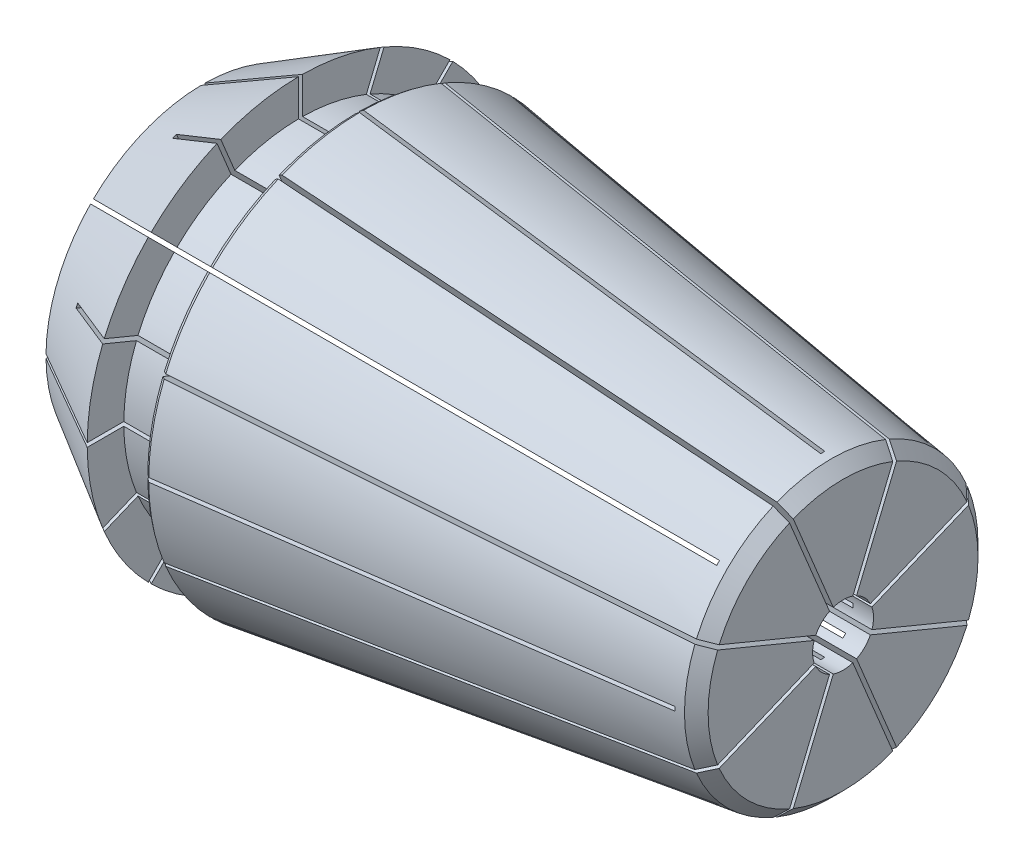
from build123d import *
from OCP.BRepFilletAPI import BRepFilletAPI_MakeChamfer

# Parameters (mm, degrees)
SKETCH2_R               = 10.5
BOSS_EXTRUDE1_DEPTH     = 31.5
CUT_EXTRUDE1_DEPTH      = 30.5
CUT_EXTRUDE2_DEPTH      = 29.5
CHAMFER_1_SIZE          = 0.5
CHAMFER_2_SIZE          = 0.2
CHAMFER_2_SIZE2         = 0.17707872296955127
CHAMFER_2_EDGE_2_SIZE   = 0.2
CHAMFER_2_EDGE_2_SIZE2  = 0.17707872296955127
CHAMFER_2_EDGE_3_SIZE2  = 0.17707872296955127
CHAMFER_2_EDGE_3_SIZE   = 0.2
CHAMFER_2_EDGE_4_SIZE2  = 0.17707872296955127
CHAMFER_2_EDGE_4_SIZE   = 0.2
CHAMFER_2_EDGE_5_SIZE2  = 0.17707872296955127
CHAMFER_2_EDGE_5_SIZE   = 0.2
CHAMFER_2_EDGE_6_SIZE2  = 0.17707872296955127
CHAMFER_2_EDGE_6_SIZE   = 0.2
CHAMFER_2_EDGE_7_SIZE2  = 0.17707872296955127
CHAMFER_2_EDGE_7_SIZE   = 0.2
CHAMFER_2_EDGE_8_SIZE2  = 0.17707872296955127
CHAMFER_2_EDGE_8_SIZE   = 0.2
CHAMFER_2_EDGE_9_SIZE2  = 0.17707872296955127
CHAMFER_2_EDGE_9_SIZE   = 0.2
CHAMFER_2_EDGE_10_SIZE2 = 0.17707872296955127
CHAMFER_2_EDGE_10_SIZE  = 0.2
CHAMFER_2_EDGE_11_SIZE2 = 0.17707872296955127
CHAMFER_2_EDGE_11_SIZE  = 0.2
CHAMFER_2_EDGE_12_SIZE2 = 0.17707872296955127
CHAMFER_2_EDGE_12_SIZE  = 0.2
CHAMFER_2_EDGE_13_SIZE2 = 0.17707872296955127
CHAMFER_2_EDGE_13_SIZE  = 0.2
CHAMFER_2_EDGE_14_SIZE2 = 0.17707872296955127
CHAMFER_2_EDGE_14_SIZE  = 0.2
CHAMFER_2_EDGE_15_SIZE2 = 0.17707872296955124
CHAMFER_2_EDGE_15_SIZE  = 0.2
CHAMFER_2_EDGE_16_SIZE2 = 0.17707872296955127
CHAMFER_2_EDGE_16_SIZE  = 0.2
CHAMFER_3_SIZE          = 0.5
CHAMFER_3_SIZE2         = 0.5874785058397357


with BuildPart() as part:
    # Sketch2 → Boss-Extrude1 (new body)
    with BuildSketch(Plane(origin=(0, 0, 0), x_dir=(0, 0, -1), z_dir=(1, 0, 0))):
        Circle(SKETCH2_R)
    extrude(amount=BOSS_EXTRUDE1_DEPTH)

    # Sketch3 → Cut-Revolve1 (revolve, cut)
    with BuildSketch(Plane.XY, mode=Mode.PRIVATE) as cut_revolve1_sk:
        Polygon((0, 7.7287187078898345), (4.799999999999999, 10.5), (4.8, 8.7), (7.602315138807671, 8.7), (7.602315138807672, 10.5), (31.5, 7.141399422153533), (31.5, 15.5), (0, 15.499999999999996), align=None)
        Polygon((0, 0), (31.5, 0), (31.5, 1.4999999999999993), (0, 1.5), align=None)
    revolve(cut_revolve1_sk.sketch.rotate(Axis((0, 0, 0), (1, 0, 0)), 90), axis=Axis((0, 0, 0), (1, 0, 0)), mode=Mode.SUBTRACT)

    # Sketch4 → Cut-Extrude1 (cut)
    with BuildSketch(Plane.ZY):
        Polygon((21.849599538664314, 21.991020894901638), (21.99102089490162, 21.849599538664325), (-21.849599538664314, -21.991020894901634), (-21.991020894901624, -21.84959953866433), align=None)
        Polygon((-0.10000000000000568, 31), (0.09999999999999433, 31), (0.1000000000000019, -31), (-0.0999999999999981, -31), align=None)
        Polygon((31, 0.10000000000000756), (31, -0.09999999999999246), (-31, -0.10000000000001143), (-31, 0.09999999999998858), align=None)
        Polygon((21.991020894901634, -21.84959953866431), (21.849599538664325, -21.99102089490162), (-21.991020894901634, 21.84959953866431), (-21.849599538664325, 21.991020894901617), align=None)
    extrude(amount=-CUT_EXTRUDE1_DEPTH, mode=Mode.SUBTRACT)

    # Sketch5 → Cut-Extrude2 (cut)
    with BuildSketch(Plane(origin=(31.5, 0, 0), x_dir=(0, 0, -1), z_dir=(1, 0, 0))):
        Polygon((-11.95557435660571, -28.601997164702777), (-11.770798450103456, -28.67853385117579), (11.955574356605666, 28.601997164702674), (11.770798450103404, 28.67853385117568), align=None)
        Polygon((28.60199716470252, 11.95557435660602), (28.678533851175544, 11.770798450103763), (-28.60199716470259, -11.955574356606142), (-28.678533851175608, -11.770798450103886), align=None)
        Polygon((28.678533851175693, -11.770798450103486), (28.601997164702688, -11.955574356605748), (-28.67853385117578, 11.77079845010337), (-28.601997164702762, 11.955574356605625), align=None)
        Polygon((11.955574356606032, -28.601997164702603), (11.770798450103777, -28.67853385117563), (-11.955574356606128, 28.601997164702507), (-11.770798450103872, 28.678533851175526), align=None)
    extrude(amount=-CUT_EXTRUDE2_DEPTH, mode=Mode.SUBTRACT)

    # Фаска1
    chamfer_1_edges = [part.edges().sort_by_distance(p)[0] for p in [
        (0, 1.3858192987669309, 0.5740251485476324),
        (0, 1.3858192987669282, -0.5740251485476393),
        (0, 0.5740251485476435, -1.3858192987669264),
        (0, -0.5740251485476404, -1.3858192987669278),
        (0, -1.3858192987669284, -0.5740251485476388),
        (0, -1.3858192987669316, 0.5740251485476311),
        (0, -0.574025148547668, 1.3858192987669162),
        (0, 0.5740251485476455, 1.3858192987669256),
    ]]
    chamfer(chamfer_1_edges, length=CHAMFER_1_SIZE)

    # Фаска2
    chamfer_2_edges = [part.edges().sort_by_distance(p)[0] for p in [
        (7.602315138807672, 2.048448381169277, 10.298245444233935),
    ]]
    chamfer_2_side = [part.faces().sort_by_distance(p)[0] for p in [
        (19.5511575694038, -1.0654e-13, 8.820699711076772),
    ]]
    chamfer(chamfer_2_edges, length=CHAMFER_2_SIZE, length2=CHAMFER_2_SIZE2, reference=chamfer_2_side[0])

    # Фаска2 edge 2
    chamfer_2_edge_2_edges = [part.edges().sort_by_distance(p)[0] for p in [
        (7.602315138807672, -2.048448381169412, 10.298245444233906),
    ]]
    chamfer_2_edge_2_side = [part.faces().sort_by_distance(p)[0] for p in [
        (19.5511575694038, -1.0654e-13, 8.820699711076772),
    ]]
    chamfer(chamfer_2_edge_2_edges, length=CHAMFER_2_EDGE_2_SIZE, length2=CHAMFER_2_EDGE_2_SIZE2, reference=chamfer_2_edge_2_side[0])

    # Фаска2 edge 3
    chamfer_2_edge_3_edges = [part.edges().sort_by_distance(p)[0] for p in [
        (7.602315138807672, -10.298245444233917, -2.0484483811693566),
    ]]
    chamfer(chamfer_2_edge_3_edges, length=CHAMFER_2_EDGE_3_SIZE, length2=CHAMFER_2_EDGE_3_SIZE2)

    # Фаска2 edge 4
    chamfer_2_edge_4_edges = [part.edges().sort_by_distance(p)[0] for p in [
        (7.602315138807672, -5.833487446705824, -8.730430929176725),
    ]]
    chamfer(chamfer_2_edge_4_edges, length=CHAMFER_2_EDGE_4_SIZE, length2=CHAMFER_2_EDGE_4_SIZE2)

    # Фаска2 edge 5
    chamfer_2_edge_5_edges = [part.edges().sort_by_distance(p)[0] for p in [
        (7.602315138807672, 2.0484483811693597, -10.298245444233917),
    ]]
    chamfer(chamfer_2_edge_5_edges, length=CHAMFER_2_EDGE_5_SIZE, length2=CHAMFER_2_EDGE_5_SIZE2)

    # Фаска2 edge 6
    chamfer_2_edge_6_edges = [part.edges().sort_by_distance(p)[0] for p in [
        (7.602315138807672, 8.730430929176745, -5.833487446705794),
    ]]
    chamfer(chamfer_2_edge_6_edges, length=CHAMFER_2_EDGE_6_SIZE, length2=CHAMFER_2_EDGE_6_SIZE2)

    # Фаска2 edge 7
    chamfer_2_edge_7_edges = [part.edges().sort_by_distance(p)[0] for p in [
        (7.602315138807672, 10.298245444233906, 2.0484483811694094),
    ]]
    chamfer(chamfer_2_edge_7_edges, length=CHAMFER_2_EDGE_7_SIZE, length2=CHAMFER_2_EDGE_7_SIZE2)

    # Фаска2 edge 8
    chamfer_2_edge_8_edges = [part.edges().sort_by_distance(p)[0] for p in [
        (7.602315138807672, 5.833487446705764, 8.730430929176766),
    ]]
    chamfer(chamfer_2_edge_8_edges, length=CHAMFER_2_EDGE_8_SIZE, length2=CHAMFER_2_EDGE_8_SIZE2)

    # Фаска2 edge 9
    chamfer_2_edge_9_edges = [part.edges().sort_by_distance(p)[0] for p in [
        (7.602315138807672, -8.730430929176746, 5.833487446705792),
    ]]
    chamfer(chamfer_2_edge_9_edges, length=CHAMFER_2_EDGE_9_SIZE, length2=CHAMFER_2_EDGE_9_SIZE2)

    # Фаска2 edge 10
    chamfer_2_edge_10_edges = [part.edges().sort_by_distance(p)[0] for p in [
        (7.602315138807672, 8.730430929176688, 5.8334874467058775),
    ]]
    chamfer(chamfer_2_edge_10_edges, length=CHAMFER_2_EDGE_10_SIZE, length2=CHAMFER_2_EDGE_10_SIZE2)

    # Фаска2 edge 11
    chamfer_2_edge_11_edges = [part.edges().sort_by_distance(p)[0] for p in [
        (7.602315138807672, 10.298245444233928, -2.0484483811693117),
    ]]
    chamfer(chamfer_2_edge_11_edges, length=CHAMFER_2_EDGE_11_SIZE, length2=CHAMFER_2_EDGE_11_SIZE2)

    # Фаска2 edge 12
    chamfer_2_edge_12_edges = [part.edges().sort_by_distance(p)[0] for p in [
        (7.602315138807672, 5.833487446705838, -8.730430929176714),
    ]]
    chamfer(chamfer_2_edge_12_edges, length=CHAMFER_2_EDGE_12_SIZE, length2=CHAMFER_2_EDGE_12_SIZE2)

    # Фаска2 edge 13
    chamfer_2_edge_13_edges = [part.edges().sort_by_distance(p)[0] for p in [
        (7.602315138807672, -2.0484483811693432, -10.298245444233922),
    ]]
    chamfer(chamfer_2_edge_13_edges, length=CHAMFER_2_EDGE_13_SIZE, length2=CHAMFER_2_EDGE_13_SIZE2)

    # Фаска2 edge 14
    chamfer_2_edge_14_edges = [part.edges().sort_by_distance(p)[0] for p in [
        (7.602315138807672, -8.730430929176716, -5.833487446705835),
    ]]
    chamfer(chamfer_2_edge_14_edges, length=CHAMFER_2_EDGE_14_SIZE, length2=CHAMFER_2_EDGE_14_SIZE2)

    # Фаска2 edge 15
    chamfer_2_edge_15_edges = [part.edges().sort_by_distance(p)[0] for p in [
        (7.602315138807672, -10.29824544423393, 2.048448381169305),
    ]]
    chamfer(chamfer_2_edge_15_edges, length=CHAMFER_2_EDGE_15_SIZE, length2=CHAMFER_2_EDGE_15_SIZE2)

    # Фаска2 edge 16
    chamfer_2_edge_16_edges = [part.edges().sort_by_distance(p)[0] for p in [
        (7.602315138807672, -5.833487446705883, 8.730430929176684),
    ]]
    chamfer(chamfer_2_edge_16_edges, length=CHAMFER_2_EDGE_16_SIZE, length2=CHAMFER_2_EDGE_16_SIZE2)

    # Фаска3: one chamfer whose edges measure the first distance from different faces: ONE call of the kernel's chamfer builder (chamfer() names one face for all edges)
    chamfer_3_edges_1 = [part.edges().sort_by_distance(p)[0] for p in [
        (31.5, -7.141399422153533, -1.463e-14),
    ]]
    chamfer_3_side_1 = [part.faces().sort_by_distance(p)[0] for p in [
        (31.5, -4.858669608876058, -1.13e-15),
    ]]
    chamfer_3_edges_2 = [part.edges().sort_by_distance(p)[0] for p in [
        (31.5, -5.049731958566466, -5.049731958566445),
    ]]
    chamfer_3_side_2 = [part.faces().sort_by_distance(p)[0] for p in [
        (31.5, -3.4355982279812425, -3.435598227981198),
    ]]
    chamfer_3_edges_3 = [part.edges().sort_by_distance(p)[0] for p in [
        (31.5, -5.241e-14, -7.141399422153533),
    ]]
    chamfer_3_side_3 = [part.faces().sort_by_distance(p)[0] for p in [
        (31.5, -8.344e-14, -4.858669608875965),
    ]]
    chamfer_3_edges_4 = [part.edges().sort_by_distance(p)[0] for p in [
        (31.5, 5.049731958566476, -5.049731958566435),
    ]]
    chamfer_3_side_4 = [part.faces().sort_by_distance(p)[0] for p in [
        (31.499999999999996, 3.4355982279812203, -3.435598227981198),
    ]]
    chamfer_3_edges_5 = [part.edges().sort_by_distance(p)[0] for p in [
        (31.5, 7.141399422153533, 8.035e-14),
    ]]
    chamfer_3_side_5 = [part.faces().sort_by_distance(p)[0] for p in [
        (31.500000000000004, 4.858669608876006, 6.55e-14),
    ]]
    chamfer_3_edges_6 = [part.edges().sort_by_distance(p)[0] for p in [
        (31.5, 5.049731958566372, 5.049731958566539),
    ]]
    chamfer_3_side_6 = [part.faces().sort_by_distance(p)[0] for p in [
        (31.5, 3.435598227981113, 3.4355982279812833),
    ]]
    chamfer_3_edges_7 = [part.edges().sort_by_distance(p)[0] for p in [
        (31.5, -1.0658e-13, 7.141399422153533),
    ]]
    chamfer_3_side_7 = [part.faces().sort_by_distance(p)[0] for p in [
        (31.499999999999996, -8.943e-14, 4.858669608875995),
    ]]
    chamfer_3_edges_8 = [part.edges().sort_by_distance(p)[0] for p in [
        (31.5, -5.049731958566504, 5.049731958566407),
    ]]
    chamfer_3_side_8 = [part.faces().sort_by_distance(p)[0] for p in [
        (31.500000000000004, -3.4355982279812256, 3.435598227981184),
    ]]
    chamfer_3 = BRepFilletAPI_MakeChamfer(part.part.solid().wrapped)
    for e in chamfer_3_edges_1:
        chamfer_3.Add(CHAMFER_3_SIZE, CHAMFER_3_SIZE2, e.wrapped, chamfer_3_side_1[0].wrapped)  # the first distance lies on this face
    for e in chamfer_3_edges_2:
        chamfer_3.Add(CHAMFER_3_SIZE, CHAMFER_3_SIZE2, e.wrapped, chamfer_3_side_2[0].wrapped)  # the first distance lies on this face
    for e in chamfer_3_edges_3:
        chamfer_3.Add(CHAMFER_3_SIZE, CHAMFER_3_SIZE2, e.wrapped, chamfer_3_side_3[0].wrapped)  # the first distance lies on this face
    for e in chamfer_3_edges_4:
        chamfer_3.Add(CHAMFER_3_SIZE, CHAMFER_3_SIZE2, e.wrapped, chamfer_3_side_4[0].wrapped)  # the first distance lies on this face
    for e in chamfer_3_edges_5:
        chamfer_3.Add(CHAMFER_3_SIZE, CHAMFER_3_SIZE2, e.wrapped, chamfer_3_side_5[0].wrapped)  # the first distance lies on this face
    for e in chamfer_3_edges_6:
        chamfer_3.Add(CHAMFER_3_SIZE, CHAMFER_3_SIZE2, e.wrapped, chamfer_3_side_6[0].wrapped)  # the first distance lies on this face
    for e in chamfer_3_edges_7:
        chamfer_3.Add(CHAMFER_3_SIZE, CHAMFER_3_SIZE2, e.wrapped, chamfer_3_side_7[0].wrapped)  # the first distance lies on this face
    for e in chamfer_3_edges_8:
        chamfer_3.Add(CHAMFER_3_SIZE, CHAMFER_3_SIZE2, e.wrapped, chamfer_3_side_8[0].wrapped)  # the first distance lies on this face
    add(Compound.cast(chamfer_3.Shape()), mode=Mode.REPLACE)


solid = part.part
